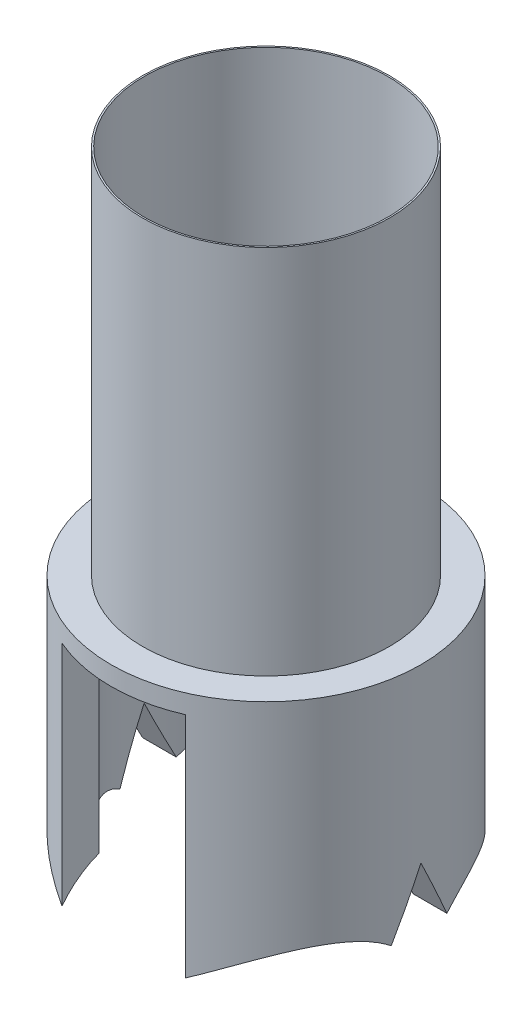
from build123d import *

# Parameters (mm, degrees)
SKETCH1_R           = 1.9939
BOSS_EXTRUDE1_DEPTH = 5.9944
SKETCH2_R           = 2.5019
BOSS_EXTRUDE2_DEPTH = 3.9878
SKETCH3_R           = 1.9685
CUT_EXTRUDE1_DEPTH  = 10.9822
SKETCH4_W           = 1.99898
SKETCH4_H           = 3.683
CUT_EXTRUDE2_DEPTH  = 6.0038
CUT_EXTRUDE3_REACH  = 7.004
CUT_EXTRUDE4_REACH  = 7.004


with BuildPart() as part:
    # Sketch1 → Boss-Extrude1 (new body)
    with BuildSketch(Plane(origin=(0, 0, 0), x_dir=(1, 0, 0), z_dir=(0, 1, 0))):
        Circle(SKETCH1_R)
    extrude(amount=BOSS_EXTRUDE1_DEPTH)

    # Sketch2 → Boss-Extrude2 (add)
    with BuildSketch(Plane(origin=(0, 0, 0), x_dir=(1, 0, 0), z_dir=(0, 1, 0))):
        Circle(SKETCH2_R)
    extrude(amount=-BOSS_EXTRUDE2_DEPTH)

    # Sketch3 → Cut-Extrude1 (cut, through all)
    with BuildSketch(Plane(origin=(0, 5.9944, 0), x_dir=(1, 0, 0), z_dir=(0, 1, 0))):
        Circle(SKETCH3_R)
    extrude(amount=-CUT_EXTRUDE1_DEPTH, mode=Mode.SUBTRACT)

    # Sketch4 → Cut-Extrude2 (cut, through all)
    with BuildSketch(Plane.XY.offset(2.5019)):
        with Locations((-0.00381, -2.1463)):
            Rectangle(SKETCH4_W, SKETCH4_H)
    extrude(amount=-CUT_EXTRUDE2_DEPTH, mode=Mode.SUBTRACT)

    # Sketch6 → Cut-Extrude3 (cut, up to next)
    with BuildSketch(Plane(origin=(-2.5019, 0, 0), x_dir=(0, 0, -1), z_dir=(1, 0, 0)), mode=Mode.PRIVATE) as cut_extrude3_sk1:
        with BuildLine():
            Line((-2.295239627, -3.9878), (2.295239627, -3.9878))
            ThreePointArc((2.295239627, -3.9878), (1.432460388, -3.48008017), (0.463371203, -3.731145085))
            Line((0.463371203, -3.731145085), (0, -2.771398111))
            Line((0, -2.771398111), (-0.439998736, -3.731145085))
            ThreePointArc((-0.439998736, -3.731145085), (-1.420774155, -3.475239573), (-2.295239627, -3.9878))
        make_face()
    cut_extrude3_tool1 = extrude(cut_extrude3_sk1.sketch, amount=CUT_EXTRUDE3_REACH, mode=Mode.PRIVATE) & part.part
    add(cut_extrude3_tool1.solids().sort_by_distance((-2.5019, -3.705676, 0.002257))[0], mode=Mode.SUBTRACT)

    # Sketch5 → Cut-Extrude4 (cut, up to next)
    with BuildSketch(Plane(origin=(2.5019, 0, 0), x_dir=(0, 0, -1), z_dir=(1, 0, 0)), mode=Mode.PRIVATE) as cut_extrude4_sk1:
        with BuildLine():
            Line((0.463371203, -3.731145085), (0, -2.771398111))
            Line((0, -2.771398111), (-0.439998736, -3.731145085))
            ThreePointArc((-0.439998736, -3.731145085), (-1.420774155, -3.475239573), (-2.295239627, -3.9878))
            Line((-2.295239627, -3.9878), (2.295239627, -3.9878))
            ThreePointArc((2.295239627, -3.9878), (1.432460388, -3.48008017), (0.463371203, -3.731145085))
        make_face()
    cut_extrude4_tool1 = extrude(cut_extrude4_sk1.sketch, amount=-CUT_EXTRUDE4_REACH, mode=Mode.PRIVATE) & part.part
    add(cut_extrude4_tool1.solids().sort_by_distance((2.5019, -3.705676, 0.002257))[0], mode=Mode.SUBTRACT)


solid = part.part
